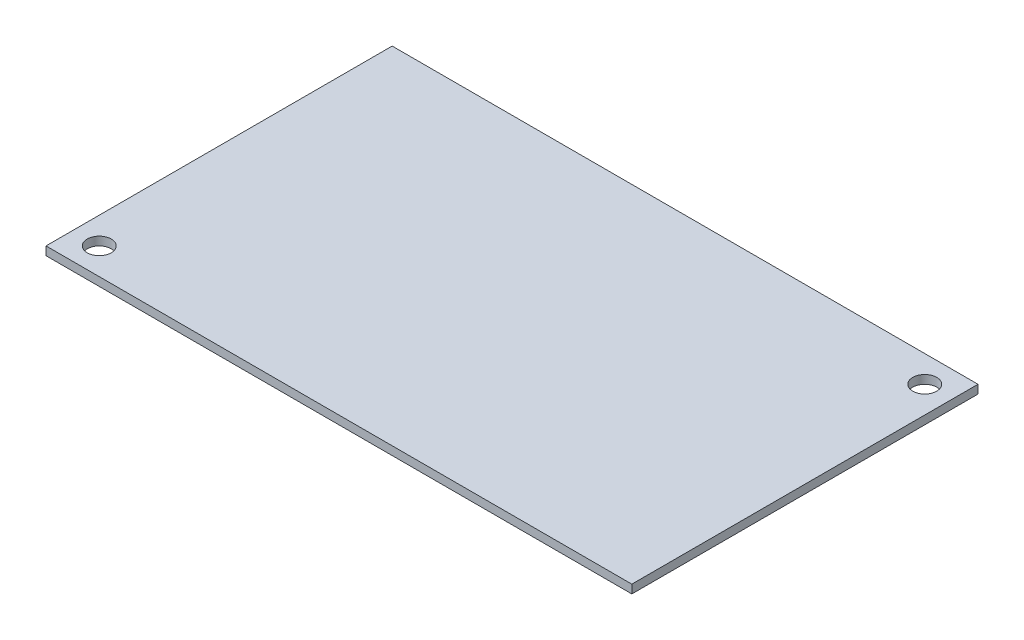
from build123d import *

# Parameters (mm, degrees)
SKETCH1_W                = 110
SKETCH1_H                = 65
BOSS_EXTRUDE1_DEPTH      = 1.6
M4_CLEARANCE_HOLE1_D     = 4.5
M4_CLEARANCE_HOLE1_DEPTH = 10.1
M4_CLEARANCE_HOLE1_TIP   = 1.351936393


with BuildPart() as part:
    # Sketch1 → Boss-Extrude1 (new body)
    with BuildSketch(Plane(origin=(0, 0, 0), x_dir=(1, 0, 0), z_dir=(0, 1, 0))):
        with Locations((55, 32.5)):
            Rectangle(SKETCH1_W, SKETCH1_H)
    extrude(amount=BOSS_EXTRUDE1_DEPTH)

    # M4 Clearance Hole1
    with Locations(Plane(origin=(0, 1.6, 0), x_dir=(1, 0, 0), z_dir=(0, 1, 0))):
        with Locations((5, 5), (105, 60)):
            Hole(M4_CLEARANCE_HOLE1_D / 2, depth=M4_CLEARANCE_HOLE1_DEPTH)
            with Locations((0, 0, -(M4_CLEARANCE_HOLE1_DEPTH + M4_CLEARANCE_HOLE1_TIP / 2))):  # 118° drill point
                Cone(0, M4_CLEARANCE_HOLE1_D / 2, M4_CLEARANCE_HOLE1_TIP, mode=Mode.SUBTRACT)


solid = part.part
